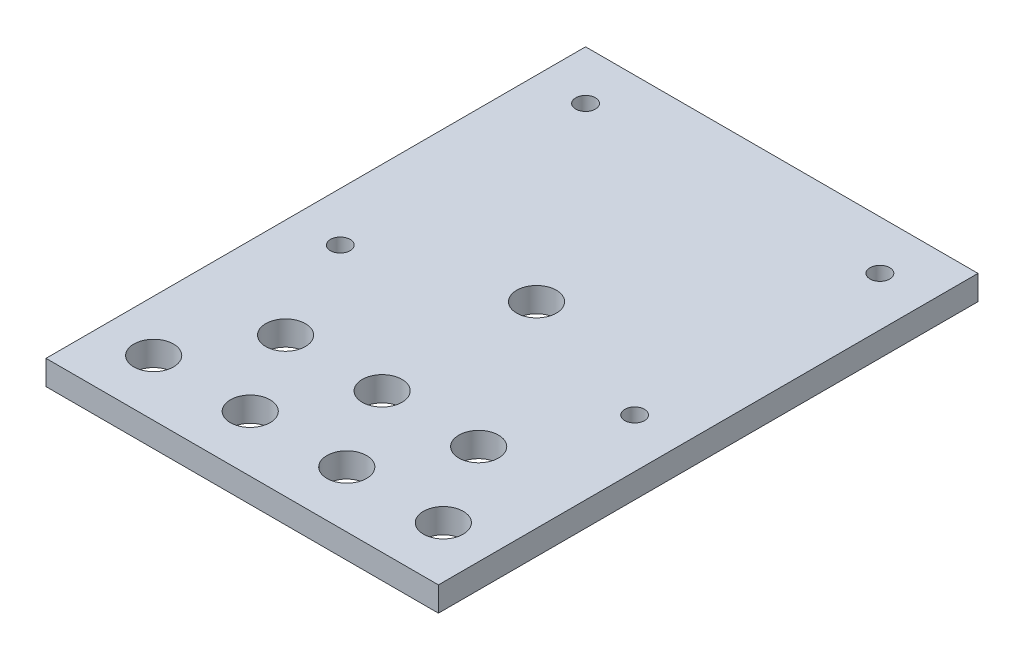
from build123d import *

# Parameters (mm, degrees)
SKETCH1_W           = 101.6
SKETCH1_H           = 139.7
BOSS_EXTRUDE1_DEPTH = 6.35
SKETCH2_R           = 5.1435
SKETCH2_R_2         = 2.55
CUT_EXTRUDE1_DEPTH  = 7.35


with BuildPart() as part:
    # Sketch1 → Boss-Extrude1 (new body)
    with BuildSketch(Plane(origin=(0, 0, 0), x_dir=(1, 0, 0), z_dir=(0, 1, 0))):
        with Locations((50.8, 69.85)):
            Rectangle(SKETCH1_W, SKETCH1_H)
    extrude(amount=BOSS_EXTRUDE1_DEPTH)

    # Sketch2 → Cut-Extrude1 (cut, through all)
    with BuildSketch(Plane(origin=(0, 6.35, 0), x_dir=(1, 0, 0), z_dir=(0, 1, 0))):
        with Locations((13.3, 14.574682453)):
            Circle(SKETCH2_R)
        with Locations((38.3, 14.574682453)):
            Circle(SKETCH2_R)
        with Locations((63.3, 14.574682453)):
            Circle(SKETCH2_R)
        with Locations((88.3, 14.574682453)):
            Circle(SKETCH2_R)
        with Locations((75.8, 36.225317547)):
            Circle(SKETCH2_R)
        with Locations((50.8, 36.225317547)):
            Circle(SKETCH2_R)
        with Locations((25.8, 36.225317547)):
            Circle(SKETCH2_R)
        with Locations((12.7, 63.5)):
            Circle(SKETCH2_R_2)
        with Locations((12.7, 127)):
            Circle(SKETCH2_R_2)
        with Locations((88.9, 63.5)):
            Circle(SKETCH2_R_2)
        with Locations((88.9, 127)):
            Circle(SKETCH2_R_2)
        with Locations((50.8, 76.2)):
            Circle(SKETCH2_R)
    extrude(amount=-CUT_EXTRUDE1_DEPTH, mode=Mode.SUBTRACT)


solid = part.part
